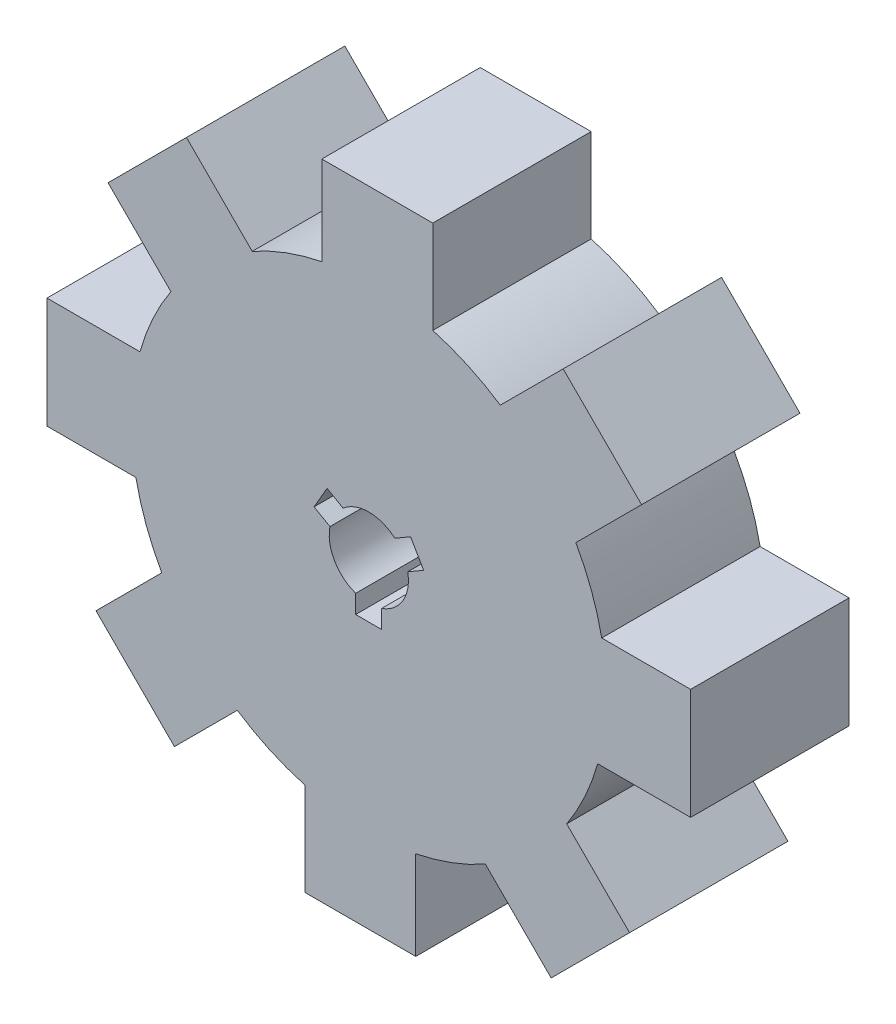
from build123d import *

# Parameters (mm, degrees)
EXTRUSION2_DEPTH = 12.7


with BuildPart() as part:
    # Sketch1 → Extrusion2 (new body)
    with BuildSketch(Plane.XY):
        with BuildLine():
            Line((15.584253212, 20.907446686), (10.543218779, 15.866412253))
            ThreePointArc((10.543218779, 15.866412253), (7.93326935, 17.319518972), (5.128249951, 18.346758636))
            Line((5.128249951, 18.346758636), (5.128249951, 25.803528454))
            Line((5.128249951, 25.803528454), (-3.764066203, 25.803528454))
            Line((-3.764066203, 25.803528454), (-3.764066203, 18.674429191))
            ThreePointArc((-3.764066203, 18.674429191), (-6.637080757, 17.856417866), (-9.346897128, 16.59933776))
            Line((-9.346897128, 16.59933776), (-14.619629632, 21.872070265))
            Line((-14.619629632, 21.872070265), (-20.907446686, 15.584253212))
            Line((-20.907446686, 15.584253212), (-15.866412253, 10.543218779))
            ThreePointArc((-15.866412253, 10.543218779), (-17.319518972, 7.93326935), (-18.346758636, 5.128249951))
            Line((-18.346758636, 5.128249951), (-25.803528454, 5.128249951))
            Line((-25.803528454, 5.128249951), (-25.803528454, -3.764066203))
            Line((-25.803528454, -3.764066203), (-18.674429191, -3.764066203))
            ThreePointArc((-18.674429191, -3.764066203), (-17.856417866, -6.637080757), (-16.59933776, -9.346897128))
            Line((-16.59933776, -9.346897128), (-21.872070265, -14.619629632))
            Line((-21.872070265, -14.619629632), (-15.584253212, -20.907446686))
            Line((-15.584253212, -20.907446686), (-10.543218779, -15.866412253))
            ThreePointArc((-10.543218779, -15.866412253), (-7.93326935, -17.319518972), (-5.128249951, -18.346758636))
            Line((-5.128249951, -18.346758636), (-5.128249951, -25.803528454))
            Line((-5.128249951, -25.803528454), (3.764066203, -25.803528454))
            Line((3.764066203, -25.803528454), (3.764066203, -18.674429191))
            ThreePointArc((3.764066203, -18.674429191), (6.637080757, -17.856417866), (9.346897128, -16.59933776))
            Line((9.346897128, -16.59933776), (14.619629632, -21.872070265))
            Line((14.619629632, -21.872070265), (20.907446686, -15.584253212))
            Line((20.907446686, -15.584253212), (15.866412253, -10.543218779))
            ThreePointArc((15.866412253, -10.543218779), (17.319518972, -7.93326935), (18.346758636, -5.128249951))
            Line((18.346758636, -5.128249951), (25.803528454, -5.128249951))
            Line((25.803528454, -5.128249951), (25.803528454, 3.764066203))
            Line((25.803528454, 3.764066203), (18.674429191, 3.764066203))
            ThreePointArc((18.674429191, 3.764066203), (17.856417866, 6.637080757), (16.59933776, 9.346897128))
            Line((16.59933776, 9.346897128), (21.872070265, 14.619629632))
            Line((21.872070265, 14.619629632), (15.584253212, 20.907446686))
        make_face()
        with BuildLine():
            ThreePointArc((-3.116590945, 0.606206137), (-2.754939335, -1.578269388), (-1.053419361, -2.995151524))
            Line((-1.053419361, -2.995151524), (-1.053419361, -4.468974981))
            Line((-1.053419361, -4.468974981), (1.033305558, -4.468974981))
            Line((1.033305558, -4.468974981), (1.033305558, -3.00215))
            ThreePointArc((1.033305558, -3.00215), (2.744291052, -1.596712756), (3.120586988, 0.585287835))
            Line((3.120586988, 0.585287835), (4.396955543, 1.322199563))
            Line((4.396955543, 1.322199563), (3.353593084, 3.129356353))
            Line((3.353593084, 3.129356353), (2.083285387, 2.395943863))
            ThreePointArc((2.083285387, 2.395943863), (0.010648283, 3.174982144), (-2.067167627, 2.409863689))
            Line((-2.067167627, 2.409863689), (-3.343536182, 3.146775418))
            Line((-3.343536182, 3.146775418), (-4.386898641, 1.339618628))
            Line((-4.386898641, 1.339618628), (-3.116590945, 0.606206137))
        make_face(mode=Mode.SUBTRACT)
    extrude(amount=EXTRUSION2_DEPTH)


solid = part.part
